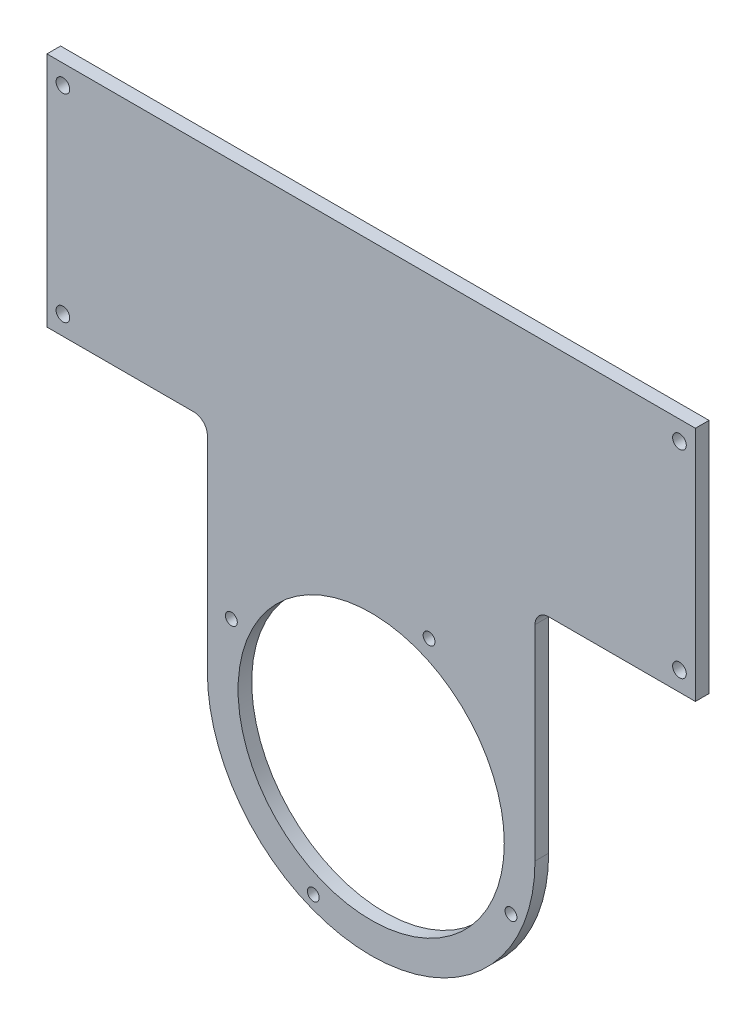
from build123d import *

# Parameters (mm, degrees)
SKETCH1_R           = 1.5
BOSS_EXTRUDE1_DEPTH = 3
FILLET1_R           = 3
SKETCH2_R           = 29.25
SKETCH2_R_2         = 1.3
CUT_EXTRUDE1_DEPTH  = 3


with BuildPart() as part:
    # Sketch1 → Boss-Extrude1 (new body)
    with BuildSketch(Plane.XY):
        with BuildLine():
            Line((-36, 0), (-36, 48))
            Line((-36, 48), (-71.25, 48))
            Line((-71.25, 48), (-71.25, 100))
            Line((-71.25, 100), (71.25, 100))
            Line((71.25, 100), (71.25, 48))
            Line((71.25, 48), (36, 48))
            Line((36, 48), (36, 0))
            ThreePointArc((36, 0), (0, -36), (-36, 0))
        make_face()
        with Locations((-67.75, 95.75)):
            Circle(SKETCH1_R, mode=Mode.SUBTRACT)
        with Locations((67.75, 95.75)):
            Circle(SKETCH1_R, mode=Mode.SUBTRACT)
        with Locations((67.75, 52.25)):
            Circle(SKETCH1_R, mode=Mode.SUBTRACT)
        with Locations((-67.75, 52.25)):
            Circle(SKETCH1_R, mode=Mode.SUBTRACT)
    extrude(amount=BOSS_EXTRUDE1_DEPTH)

    # Fillet1
    fillet1_edges = [part.edges().sort_by_distance(p)[0] for p in [
        (36, 48, 1.5),
        (-36, 48, 1.5),
    ]]
    fillet(fillet1_edges, radius=FILLET1_R)

    # Sketch2 → Cut-Extrude1 (cut)
    with BuildSketch(Plane.XY.offset(3)):
        Circle(SKETCH2_R)
        with Locations((12.724224126, 30.718994456)):
            Circle(SKETCH2_R_2)
        with Locations((30.718994456, -12.724224126)):
            Circle(SKETCH2_R_2)
        with Locations((-12.724224126, -30.718994456)):
            Circle(SKETCH2_R_2)
        with Locations((-30.718994456, 12.724224126)):
            Circle(SKETCH2_R_2)
    extrude(amount=-CUT_EXTRUDE1_DEPTH, mode=Mode.SUBTRACT)


solid = part.part
